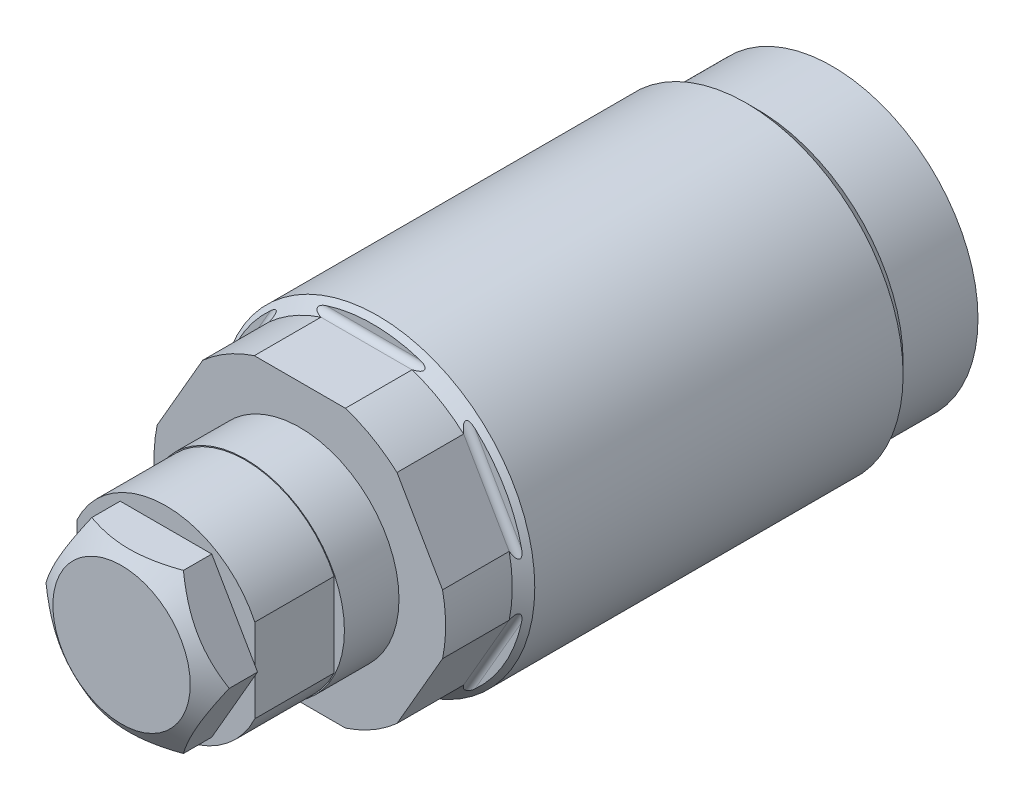
from build123d import *

# Parameters (mm, degrees)
SKETCH1_R           = 12.573
EXTRUDE1_DEPTH      = 42.6212
CUT_EXTRUDE1_DEPTH  = 15.0876
SKETCH12_W          = 10.7188
SKETCH12_H          = 7.9375
S2D0011_W           = 3.4544
S2D0011_H           = 4.826
CUT_EXTRUDE10_DEPTH = 6.35
EXTRUDE2_DEPTH      = 3.556
CIRPATTERN2_COUNT   = 6
SKETCH18_W          = 6.35
SKETCH18_H          = 0.0762


with BuildPart() as part:
    # Sketch1 → Extrude1 (new body)
    with BuildSketch(Plane.XY):
        Circle(SKETCH1_R)
    extrude(amount=EXTRUDE1_DEPTH)

    # Sketch2 → Cut-Extrude1 (cut, symmetric)
    with BuildSketch(Plane(origin=(0, 0, 0), x_dir=(0, 0, 1), z_dir=(1, 0, 0))):
        with BuildLine():
            Line((36.7792, 12.573), (36.7792, 11.5951))
            ThreePointArc((36.7792, 11.5951), (36.927989755, 11.235889755), (37.2872, 11.0871))
            Line((37.2872, 11.0871), (42.6212, 11.0871))
            Line((42.6212, 11.0871), (42.6212, 12.573))
            Line((42.6212, 12.573), (36.7792, 12.573))
        make_face()
    cut_extrude1 = extrude(amount=CUT_EXTRUDE1_DEPTH, both=True, mode=Mode.SUBTRACT)

    # Sketch10 → Cut-Revolve1 (revolve, cut)
    with BuildSketch(Plane(origin=(0, 0, 0), x_dir=(0, 0, -1), z_dir=(1, 0, 0)), mode=Mode.PRIVATE) as cut_revolve1_sk:
        Polygon((-42.6212, 11.6713), (-37.2872, 11.6713), (-36.3855, 12.573), (-42.6212, 12.573), align=None)
    revolve(cut_revolve1_sk.sketch.rotate(Axis((0, 0, 42.424985), (0, 0, -1)), 90), axis=Axis((0, 0, 42.424985), (0, 0, -1)), mode=Mode.SUBTRACT)  # turned: the seam where the file's is

    # Sketch11 → Cut-Revolve2 (revolve, cut)
    with BuildSketch(Plane(origin=(0, 0, 0), x_dir=(0, 0, 1), z_dir=(1, 0, 0)), mode=Mode.PRIVATE) as cut_revolve2_sk:
        Polygon((0, 11.6713), (5.9944, 11.6713), (6.8961, 12.573), (0, 12.573), align=None)
    revolve(cut_revolve2_sk.sketch.rotate(Axis((0, 0, -0.344805), (0, 0, 1)), 270), axis=Axis((0, 0, -0.344805), (0, 0, 1)), mode=Mode.SUBTRACT)  # turned: the seam where the file's is

    # Sketch12 → Revolve1 (revolve)
    with BuildSketch(Plane(origin=(0, 0, 0), x_dir=(0, 0, -1), z_dir=(1, 0, 0)), mode=Mode.PRIVATE) as revolve1_sk:
        with Locations((-47.9806, 3.96875)):
            Rectangle(SKETCH12_W, SKETCH12_H)
    revolve(revolve1_sk.sketch.rotate(Axis((0, 0, 53.76799), (0, 0, -1)), 270), axis=Axis((0, 0, 53.76799), (0, 0, -1)))  # turned: the seam where the file's is

    # S2D0011 → Cut-Revolve3 (revolve, cut)
    with BuildSketch(Plane(origin=(-3.4544, 0, 53.213), x_dir=(-1, 0, 0), z_dir=(0, 1, 0))):
        with Locations((-1.7272, -2.286)):
            Rectangle(S2D0011_W, S2D0011_H)
    revolve(axis=Axis((0, 0, 27.017003875), (0, 0, 1)), mode=Mode.SUBTRACT)

    # Sketch15 → Cut-Extrude10 (cut)
    with BuildSketch(Plane.YX.offset(-53.34)):
        with BuildLine():
            Line((-3.524679028, 7.112), (3.524679028, 7.112))
            ThreePointArc((3.524679028, 7.112), (0, 7.9375), (-3.524679028, 7.112))
        make_face()
        with BuildLine():
            Line((-3.524679028, -7.112), (3.524679028, -7.112))
            ThreePointArc((3.524679028, -7.112), (0, -7.9375), (-3.524679028, -7.112))
        make_face()
    extrude(amount=CUT_EXTRUDE10_DEPTH, mode=Mode.SUBTRACT)

    # Sketch16 → Extrude2 (add)
    with BuildSketch(Plane.XY.offset(53.34)):
        Polygon((-3.666174209, 6.35), (3.666174209, 6.35), (7.332348419, 0), (3.666174209, -6.35), (-3.666174209, -6.35), (-7.332348419, 0), align=None)
    extrude(amount=EXTRUDE2_DEPTH)

    # Sketch17 → Cut-Revolve4 (revolve, cut)
    with BuildSketch(Plane(origin=(0, 0, 0), x_dir=(1, 0, 0), z_dir=(0, 1, 0)), mode=Mode.PRIVATE) as cut_revolve4_sk:
        Polygon((5.4991, -56.896), (7.332348419, -55.612345638), (7.332348419, -56.896), align=None)
    revolve(cut_revolve4_sk.sketch.rotate(Axis((0, 0, 56.833182718), (0, 0, -1)), 180), axis=Axis((0, 0, 56.833182718), (0, 0, -1)), mode=Mode.SUBTRACT)  # turned: the seam where the file's is

    # CirPattern2: Cut-Extrude1 ×6 about axis
    cirpattern2_axis = Axis((0, 0, 0), (0, 0, 1))
    for i in range(1, CIRPATTERN2_COUNT):
        add(cut_extrude1.rotate(cirpattern2_axis, i * 360 / CIRPATTERN2_COUNT), mode=Mode.SUBTRACT)

    # Sketch18 → Cut-Revolve5 (revolve, cut)
    with BuildSketch(Plane(origin=(0, 0, 0), x_dir=(0, 0, -1), z_dir=(1, 0, 0)), mode=Mode.PRIVATE) as cut_revolve5_sk:
        with Locations((-50.165, 7.8994)):
            Rectangle(SKETCH18_W, SKETCH18_H)
    revolve(cut_revolve5_sk.sketch.rotate(Axis((0, 0, 0), (0, 0, 1)), 90), axis=Axis((0, 0, 0), (0, 0, 1)), mode=Mode.SUBTRACT)  # turned: the seam where the file's is


solid = part.part
